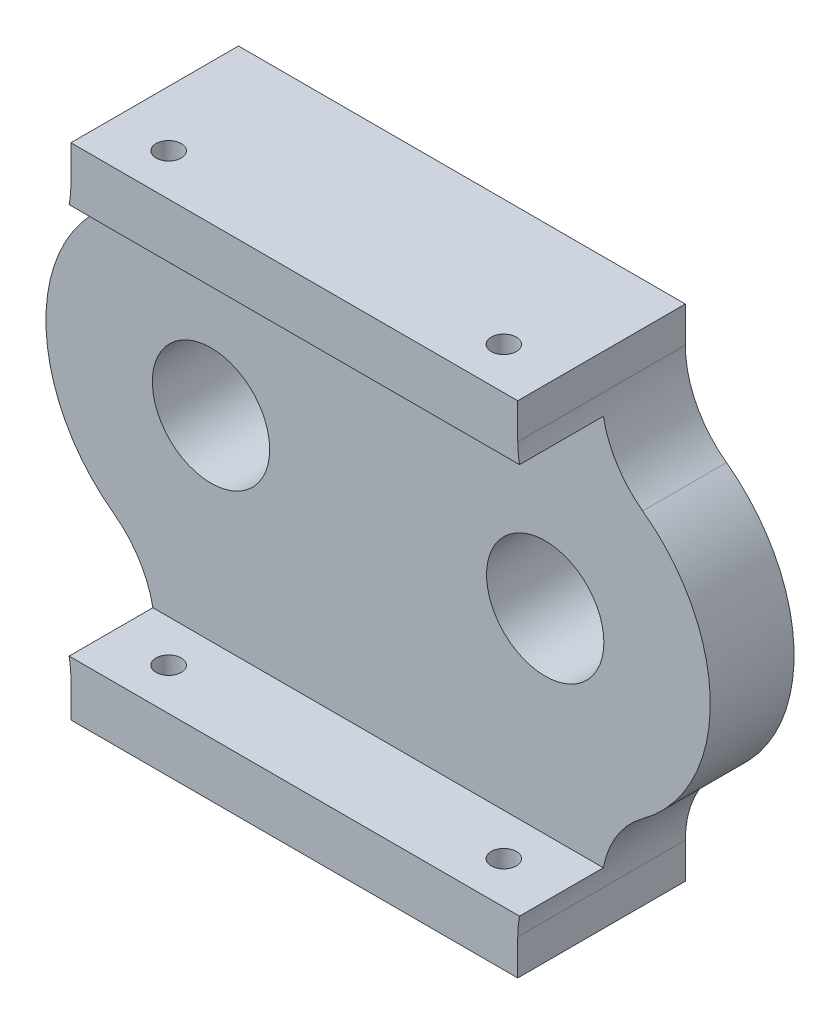
from build123d import *

# Parameters (mm, degrees)
SKETCH1_R               = 10.5
BOSS_EXTRUDE1_DEPTH     = 15
BOSS_EXTRUDE2_DEPTH     = 30
CUT_EXTRUDE1_DEPTH      = 112.566501075
CUT_EXTRUDE1_DEPTH_BACK = 112.566501075
SKETCH2_R               = 2.25


with BuildPart() as part:
    # Sketch1 → Boss-Extrude1 (new body)
    with BuildSketch(Plane.XY):
        with BuildLine():
            Line((-40.319533419, -35), (40.319533419, -35))
            ThreePointArc((40.319533419, -35), (42.786608734, -28.756118968), (47.370059804, -23.850562196))
            ThreePointArc((47.370059804, -23.850562196), (59.471288553, 0.00030559), (47.370059804, 23.851173376))
            ThreePointArc((47.370059804, 23.851173376), (42.786775017, 28.756467199), (40.31965015, 35))
            Line((40.31965015, 35), (-40.31965015, 35))
            ThreePointArc((-40.31965015, 35), (-42.786775017, 28.756467199), (-47.370059804, 23.851173376))
            ThreePointArc((-47.370059804, 23.851173376), (-59.471288553, 0.00030559), (-47.370059804, -23.850562196))
            ThreePointArc((-47.370059804, -23.850562196), (-42.786608734, -28.756118968), (-40.319533419, -35))
        make_face()
        with Locations((-29.916288553, 0.00030559)):
            Circle(SKETCH1_R, mode=Mode.SUBTRACT)
        with Locations((29.916288553, 0.00030559)):
            Circle(SKETCH1_R, mode=Mode.SUBTRACT)
    extrude(amount=BOSS_EXTRUDE1_DEPTH)

    # Sketch1_3 → Boss-Extrude2 (add)
    with BuildSketch(Plane.XY):
        with BuildLine():
            Line((40.319533419, -35), (-40.319533419, -35))
            ThreePointArc((-40.319533419, -35), (-40.080061405, -36.6807331), (-40, -38.376551713))
            Line((-40, -38.376551713), (-40, -44.75))
            Line((-40, -44.75), (40, -44.75))
            Line((40, -44.75), (40, -38.376551713))
            ThreePointArc((40, -38.376551713), (40.080061405, -36.6807331), (40.319533419, -35))
        make_face()
        with BuildLine():
            ThreePointArc((-40, 38.377162892), (-40.080090719, 36.681034549), (-40.31965015, 35))
            Line((-40.31965015, 35), (40.31965015, 35))
            ThreePointArc((40.31965015, 35), (40.080090719, 36.681034549), (40, 38.377162892))
            Line((40, 38.377162892), (40, 44.75))
            Line((40, 44.75), (-40, 44.75))
            Line((-40, 44.75), (-40, 38.377162892))
        make_face()
    extrude(amount=BOSS_EXTRUDE2_DEPTH)

    # Sketch2 → Cut-Extrude1 (cut, two sides: drawn at the far end of the back side and taken through both)
    with BuildSketch(Plane.XZ.offset(44.75).offset(-CUT_EXTRUDE1_DEPTH_BACK)):
        with Locations((-30.001288553, 22.5)):
            Circle(SKETCH2_R)
        with Locations((30.001288553, 22.5)):
            Circle(SKETCH2_R)
    extrude(amount=CUT_EXTRUDE1_DEPTH + CUT_EXTRUDE1_DEPTH_BACK, mode=Mode.SUBTRACT)


solid = part.part
